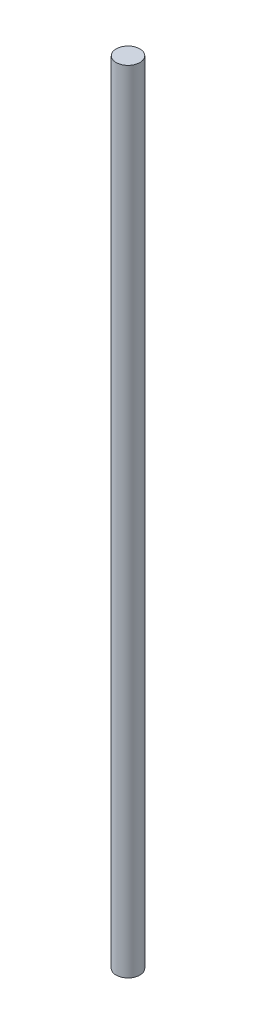
from build123d import *

# Parameters (mm, degrees)
SKETCH1_R           = 3
BOSS_EXTRUDE1_DEPTH = 200


with BuildPart() as part:
    # Sketch1 → Boss-Extrude1 (new body)
    with BuildSketch(Plane(origin=(0, 0, 0), x_dir=(1, 0, 0), z_dir=(0, 1, 0))):
        Circle(SKETCH1_R)
    extrude(amount=BOSS_EXTRUDE1_DEPTH)


solid = part.part
